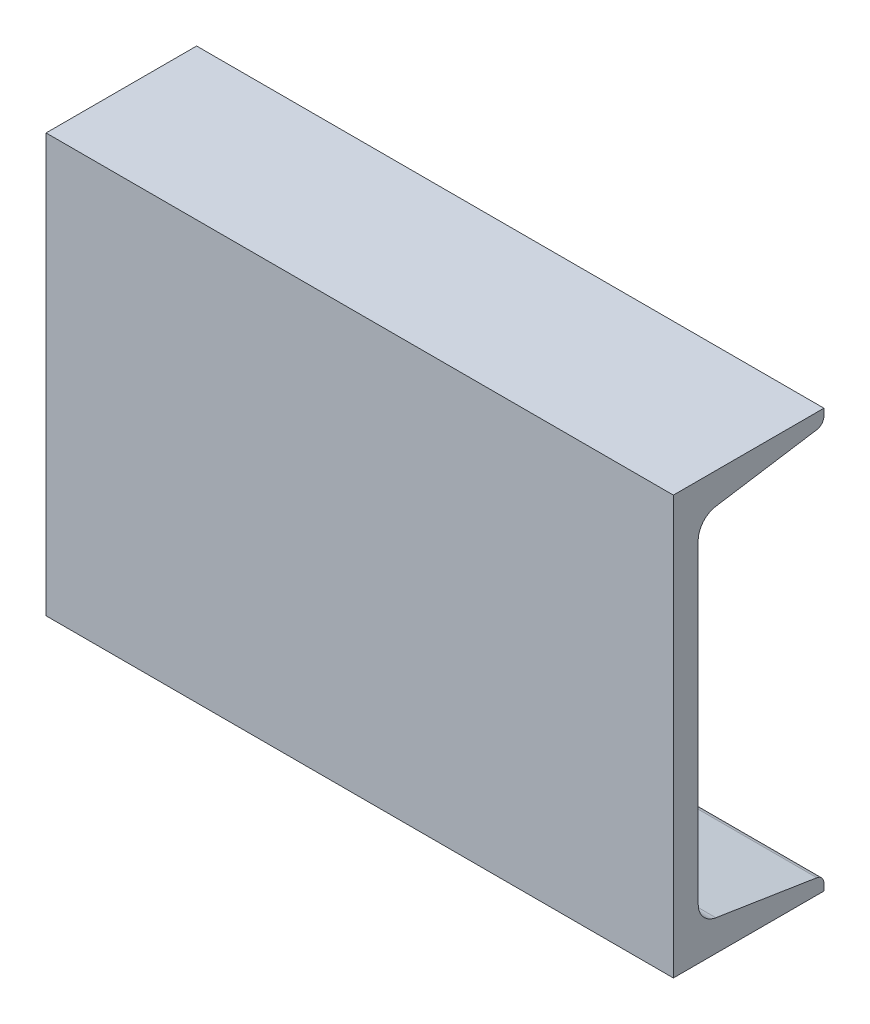
from build123d import *

# Parameters (mm, degrees)
BOSS_EXTRUDE1_DEPTH = 114.3


with BuildPart() as part:
    # Sketch1 → Boss-Extrude1 (new body, symmetric)
    with BuildSketch(Plane(origin=(0, 0, 0), x_dir=(0, 0, -1), z_dir=(1, 0, 0))):
        with BuildLine():
            Line((-25.3365, -76.2), (-25.3365, 76.2))
            Line((-25.3365, 76.2), (29.5275, 76.2))
            Line((29.5275, 76.2), (29.5275, 73.710744653))
            ThreePointArc((29.5275, 73.710744653), (28.795909131, 71.72969626), (26.952334163, 70.699643218))
            Line((26.952334163, 70.699643218), (-9.856185406, 64.919590337))
            ThreePointArc((-9.856185406, 64.919590337), (-14.465122828, 62.344457732), (-16.2941, 57.391836749))
            Line((-16.2941, 57.391836749), (-16.2941, -57.391836749))
            ThreePointArc((-16.2941, -57.391836749), (-14.465122828, -62.344457732), (-9.856185406, -64.919590337))
            Line((-9.856185406, -64.919590337), (26.952334163, -70.699643218))
            ThreePointArc((26.952334163, -70.699643218), (28.795909131, -71.72969626), (29.5275, -73.710744653))
            Line((29.5275, -73.710744653), (29.5275, -76.2))
            Line((29.5275, -76.2), (-25.3365, -76.2))
        make_face()
    extrude(amount=BOSS_EXTRUDE1_DEPTH, both=True)


solid = part.part
